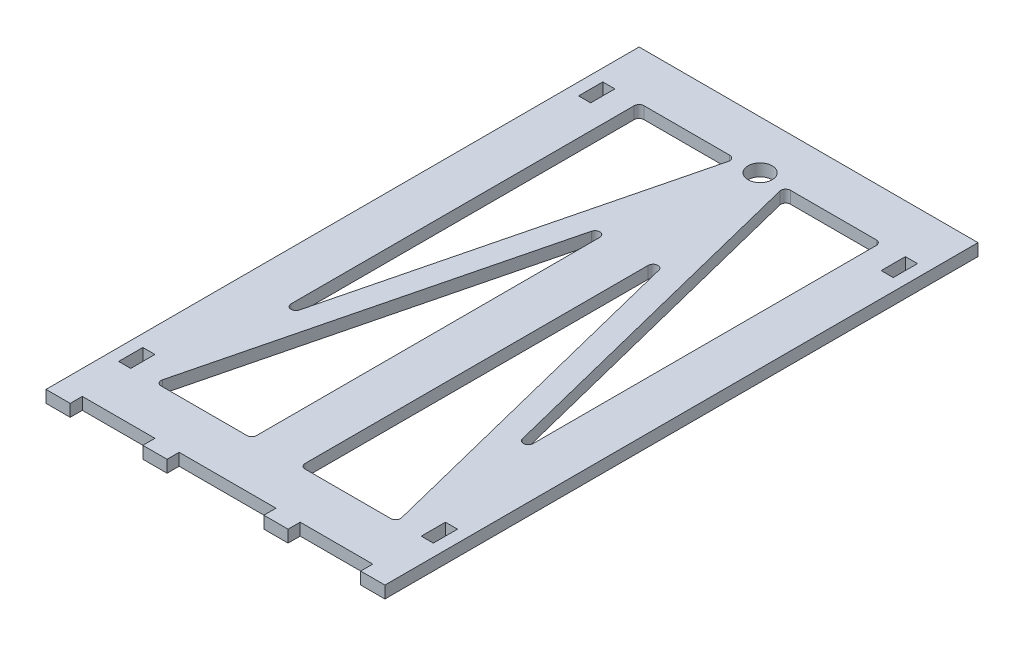
from build123d import *

# Parameters (mm, degrees)
SKETCH1_W         = 6.35
SKETCH1_H         = 12.7
SKETCH1_R         = 6.35
SKETCH1_W_2       = 12.7
SKETCH1_H_2       = 6.35
FRONT_PANEL_DEPTH = 6.35
FILLET1_R         = 2.54


with BuildPart() as part:
    # Sketch1 → Front Panel (new body)
    with BuildSketch(Plane(origin=(0, 0, 0), x_dir=(1, 0, 0), z_dir=(0, 1, 0))):
        Polygon((0, 304.8), (0, 0), (12.7, 0), (50.8, 0), (63.5, 0), (114.3, 0), (127, 0), (165.1, 0), (177.8, 0), (177.8, 304.8), align=None)
        with Locations((9.525, 31.75)):
            Rectangle(SKETCH1_W, SKETCH1_H, mode=Mode.SUBTRACT)
        Polygon((25.4, 25.4), (76.2, 228.6), (76.2, 25.4), align=None, mode=Mode.SUBTRACT)
        with Locations((168.275, 31.75)):
            Rectangle(SKETCH1_W, SKETCH1_H, mode=Mode.SUBTRACT)
        Polygon((101.6, 25.4), (101.6, 228.6), (152.4, 25.4), align=None, mode=Mode.SUBTRACT)
        Polygon((25.4, 279.4), (76.2, 279.4), (25.4, 76.2), align=None, mode=Mode.SUBTRACT)
        with Locations((9.525, 273.05)):
            Rectangle(SKETCH1_W, SKETCH1_H, mode=Mode.SUBTRACT)
        Polygon((152.4, 76.2), (101.6, 279.4), (152.4, 279.4), align=None, mode=Mode.SUBTRACT)
        with Locations((88.9, 279.4)):
            Circle(SKETCH1_R, mode=Mode.SUBTRACT)
        with Locations((168.275, 273.05)):
            Rectangle(SKETCH1_W, SKETCH1_H, mode=Mode.SUBTRACT)
        with Locations((6.35, -3.175)):
            Rectangle(SKETCH1_W_2, SKETCH1_H_2)
        with Locations((57.15, -3.175)):
            Rectangle(SKETCH1_W_2, SKETCH1_H_2)
        with Locations((120.65, -3.175)):
            Rectangle(SKETCH1_W_2, SKETCH1_H_2)
        with Locations((171.45, -3.175)):
            Rectangle(SKETCH1_W_2, SKETCH1_H_2)
    extrude(amount=FRONT_PANEL_DEPTH)

    # Fillet1
    fillet1_edges = [part.edges().sort_by_distance(p)[0] for p in [
        (76.2, 3.175, -25.4),
        (76.2, 3.175, -228.6),
        (25.4, 3.175, -25.4),
        (76.2, 3.175, -279.4),
        (25.4, 3.175, -279.4),
        (25.4, 3.175, -76.2),
        (101.6, 3.175, -228.6),
        (101.6, 3.175, -25.4),
        (152.4, 3.175, -25.4),
        (152.4, 3.175, -279.4),
        (101.6, 3.175, -279.4),
        (152.4, 3.175, -76.2),
    ]]
    fillet(fillet1_edges, radius=FILLET1_R)


solid = part.part
